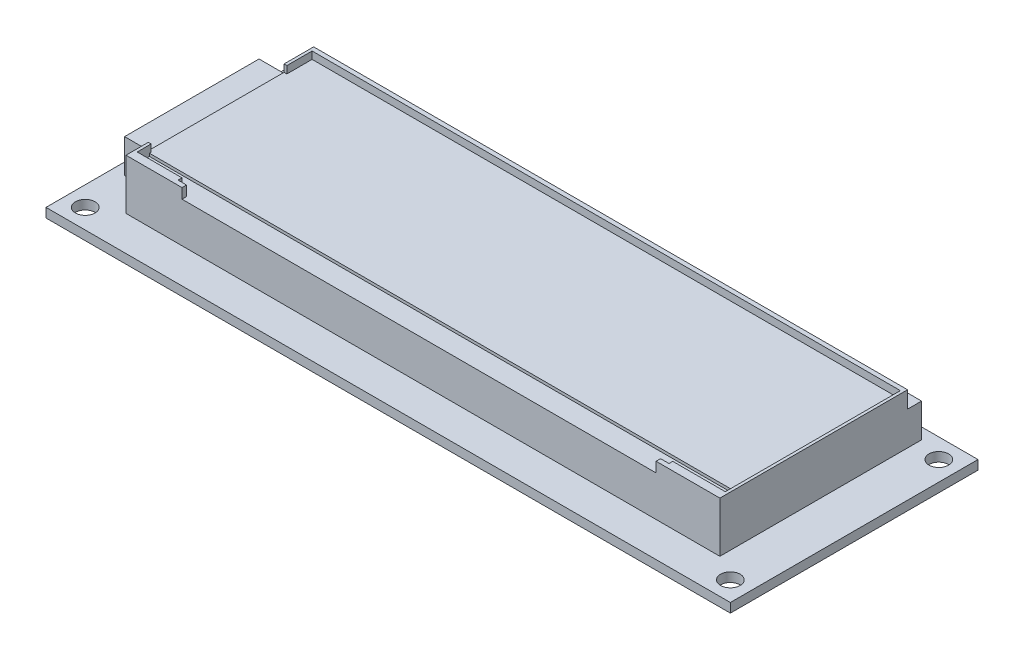
from build123d import *

# Parameters (mm, degrees)
SKETCH1_W           = 122.15
SKETCH1_H           = 44.2
SKETCH1_R           = 1.75
BOSS_EXTRUDE1_DEPTH = 1.65
SKETCH2_W           = 106
SKETCH2_H           = 36
BOSS_EXTRUDE2_DEPTH = 9
SKETCH3_W           = 106
SKETCH3_H           = 2.5
CUT_EXTRUDE1_DEPTH  = 3
CUT_EXTRUDE2_DEPTH  = 1.3
SKETCH5_W           = 6
SKETCH5_H           = 24
BOSS_EXTRUDE3_DEPTH = 6
CUT_EXTRUDE3_DEPTH  = 0.5


with BuildPart() as part:
    # Sketch1 → Boss-Extrude1 (new body)
    with BuildSketch(Plane(origin=(0, 0, 0), x_dir=(1, 0, 0), z_dir=(0, 1, 0))):
        with Locations((61.075, 22.1)):
            Rectangle(SKETCH1_W, SKETCH1_H)
        with Locations((3.5, 40.7)):
            Circle(SKETCH1_R, mode=Mode.SUBTRACT)
        with Locations((3.5, 3.5)):
            Circle(SKETCH1_R, mode=Mode.SUBTRACT)
        with Locations((118.65, 3.5)):
            Circle(SKETCH1_R, mode=Mode.SUBTRACT)
        with Locations((118.65, 40.7)):
            Circle(SKETCH1_R, mode=Mode.SUBTRACT)
    extrude(amount=BOSS_EXTRUDE1_DEPTH)

    # Sketch2 → Boss-Extrude2 (add)
    with BuildSketch(Plane(origin=(0, 1.65, 0), x_dir=(1, 0, 0), z_dir=(0, 1, 0))):
        with Locations((61.075, 24.2)):
            Rectangle(SKETCH2_W, SKETCH2_H)
    extrude(amount=BOSS_EXTRUDE2_DEPTH)

    # Sketch3 → Cut-Extrude1 (cut)
    with BuildSketch(Plane(origin=(0, 10.65, 0), x_dir=(1, 0, 0), z_dir=(0, 1, 0))):
        with Locations((61.075, 40.95)):
            Rectangle(SKETCH3_W, SKETCH3_H)
    extrude(amount=-CUT_EXTRUDE1_DEPTH, mode=Mode.SUBTRACT)

    # Sketch4 → Cut-Extrude2 (cut)
    with BuildSketch(Plane(origin=(0, 10.65, 0), x_dir=(1, 0, 0), z_dir=(0, 1, 0))):
        Polygon((16.575, 7.7), (16.575, 7), (18.075, 7), (18.075, 6.2), (102.68965461, 6.2), (102.68965461, 7), (104.18965461, 7), (104.18965461, 7.672103119), (113.575, 7.672103119), (113.575, 38.92), (8.575, 38.92), (8.575, 34.42), (8.075, 34.42), (8.075, 10.2), (8.575, 10.2), (8.575, 7.7), align=None)
    extrude(amount=-CUT_EXTRUDE2_DEPTH, mode=Mode.SUBTRACT)

    # Sketch5 → Boss-Extrude3 (add)
    with BuildSketch(Plane(origin=(0, 1.65, 0), x_dir=(1, 0, 0), z_dir=(0, 1, 0))):
        with Locations((5.075, 23.95)):
            Rectangle(SKETCH5_W, SKETCH5_H)
    extrude(amount=BOSS_EXTRUDE3_DEPTH)

    # Sketch6 → Cut-Extrude3 (cut)
    with BuildSketch(Plane(origin=(0, 9.35, 0), x_dir=(1, 0, 0), z_dir=(0, 1, 0))):
        Polygon((8.575, 7.7), (8.575, 9.9), (113.575, 9.9), (113.575, 7.672103119), (104.18965461, 7.672103119), (104.18965461, 7), (102.68965461, 7), (102.68965461, 6.2), (18.075, 6.2), (18.075, 7), (16.575, 7), (16.575, 7.7), align=None)
    extrude(amount=-CUT_EXTRUDE3_DEPTH, mode=Mode.SUBTRACT)


solid = part.part
